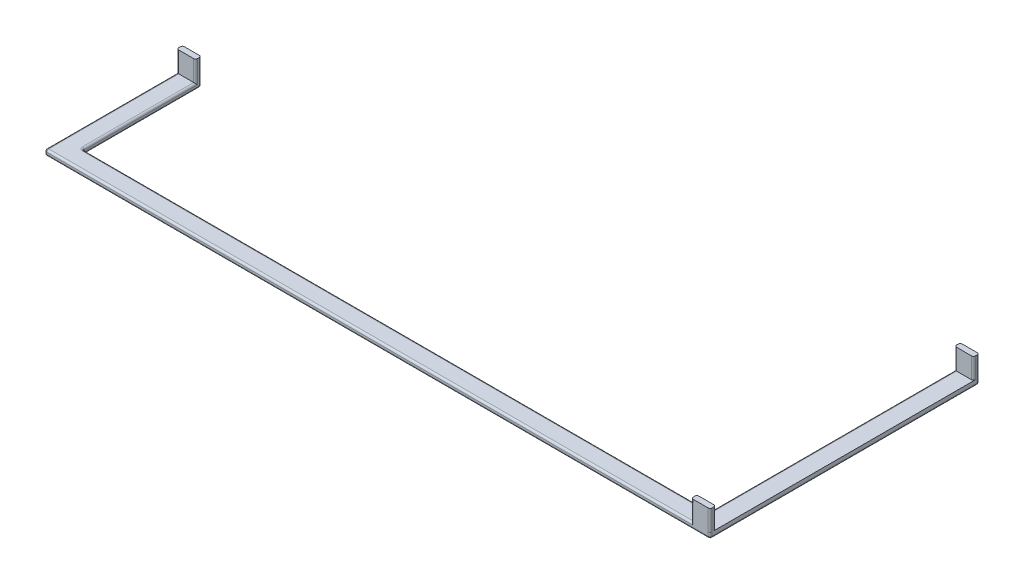
from build123d import *

# Parameters (mm, degrees)
BOSS_EXTRU_1_DEPTH   = 11
BOSS_EXTRU_1_2_DEPTH = 11
BOSS_EXTRU_2_DEPTH   = 3
BOSS_EXTRU_4_DEPTH   = 343.6
BOSS_EXTRU_5_DEPTH   = 63.11
BOSS_EXTRU_6_DEPTH   = 11
CONG_1_R             = 1
CONG_2_R             = 1


with BuildPart() as part:
    # Esquisse1 → Boss.-Extru.1 (new body)
    with BuildSketch(Plane(origin=(0, 0, 0), x_dir=(1, 0, 0), z_dir=(0, 1, 0))):
        with BuildLine():
            Line((0.9999999999999831, 71.50000000000001), (8.999999999999984, 71.50000000000001))
            ThreePointArc((8.999999999999984, 71.50000000000001), (9.707106781186543, 71.20710678118655), (9.999999999999984, 70.5))
            Line((9.999999999999984, 70.5), (9.999999999999984, 69.5))
            ThreePointArc((9.999999999999984, 69.5), (9.707106781186532, 68.79289321881345), (8.999999999999984, 68.5))
            Line((8.999999999999984, 68.5), (0.9999999999999831, 68.5))
            ThreePointArc((0.9999999999999831, 68.5), (0.2928932188134351, 68.79289321881345), (-1.735e-14, 69.5))
            Line((-1.735e-14, 69.5), (-1.735e-14, 70.5))
            ThreePointArc((-1.735e-14, 70.5), (0.29289321881342556, 71.20710678118655), (0.9999999999999831, 71.50000000000001))
        make_face()
    extrude(amount=BOSS_EXTRU_1_DEPTH)



with BuildPart() as body_2:
    # Esquisse1 → Boss.-Extru.1 2 (new body)
    with BuildSketch(Plane(origin=(0, 0, 0), x_dir=(1, 0, 0), z_dir=(0, 1, 0))):
        with BuildLine():
            Line((1.0000000000000004, -68.5), (9.000000000000002, -68.5))
            ThreePointArc((9.000000000000002, -68.5), (9.70710678118655, -68.79289321881345), (10.000000000000002, -69.5))
            Line((10.000000000000002, -69.5), (10.000000000000002, -70.5))
            ThreePointArc((10.000000000000002, -70.5), (9.70710678118656, -71.20710678118655), (9.000000000000002, -71.50000000000001))
            Line((9.000000000000002, -71.50000000000001), (1.0000000000000004, -71.50000000000001))
            ThreePointArc((1.0000000000000004, -71.50000000000001), (0.2928932188134524, -71.20710678118655), (0, -70.5))
            Line((0, -70.5), (0, -69.5))
            ThreePointArc((0, -69.5), (0.292893218813453, -68.79289321881345), (1.0000000000000004, -68.5))
        make_face()
    extrude(amount=BOSS_EXTRU_1_2_DEPTH)


with BuildPart() as part_1:
    add(part.part)

    add(body_2.part)  # Boss.-Extru.2 merges body 2
    # Esquisse2 → Boss.-Extru.2 (add)
    with BuildSketch(Plane.XZ):
        Polygon((-1.727e-14, 71.50000000000001), (9.999999999999984, 71.50000000000001), (10.000000000000002, -71.50000000000001), (2.4e-16, -71.50000000000001), align=None)
    extrude(amount=BOSS_EXTRU_2_DEPTH)

    # Esquisse3 → Boss.-Extru.4 (add)
    with BuildSketch(Plane(origin=(0, 0, 0), x_dir=(0, 0, -1), z_dir=(1, 0, 0))):
        Polygon((-61.50000000000001, -2.9999999999999996), (-71.50000000000001, -3.0000000000000013), (-71.50000000000001, -1.751e-14), (-61.5, -1.648e-14), align=None)
    extrude(amount=-BOSS_EXTRU_4_DEPTH)

    # Esquisse4 → Boss.-Extru.5 (add)
    with BuildSketch(Plane(origin=(0, 1.4225e-13, 61.5), x_dir=(-1, 0, 0), z_dir=(0, -3.47e-15, -1))):
        Polygon((343.6, -3.0000000000001417), (333.6, -3.000000000000143), (333.6, -2.2985e-13), (343.6, -2.2985e-13), align=None)
    extrude(amount=BOSS_EXTRU_5_DEPTH)

    # Esquisse5 → Boss.-Extru.6 (add)
    with BuildSketch(Plane(origin=(0, 0, 0), x_dir=(1, 0, 0), z_dir=(0, 1, 0))):
        with BuildLine():
            Line((-342.6, 1.6100000000000003), (-334.6, 1.6100000000000003))
            ThreePointArc((-334.6, 1.6100000000000003), (-333.89289321881347, 1.3171067811865478), (-333.6, 0.6100000000000004))
            Line((-333.6, 0.6100000000000004), (-333.6, -0.38999999999999974))
            ThreePointArc((-333.6, -0.38999999999999974), (-333.89289321881347, -1.0971067811865471), (-334.6, -1.3899999999999997))
            Line((-334.6, -1.3899999999999997), (-342.6, -1.3899999999999997))
            ThreePointArc((-342.6, -1.3899999999999997), (-343.3071067811866, -1.0971067811865471), (-343.6, -0.38999999999999974))
            Line((-343.6, -0.38999999999999974), (-343.6, 0.6100000000000001))
            ThreePointArc((-343.6, 0.6100000000000001), (-343.3071067811866, 1.3171067811865478), (-342.6, 1.6100000000000003))
        make_face()
    extrude(amount=BOSS_EXTRU_6_DEPTH)

    # Congé1
    cong_1_edges = [part_1.edges().sort_by_distance(p)[0] for p in [
        (-333.6, -1.5000000000002631, -1.6099999999999943),
        (-343.6, -1.5000000000002622, -1.6099999999999943),
        (-343.6, -1.5000000000000093, 71.50000000000001),
        (-333.6, -1.5000000000000442, 61.50000000000001),
        (0, -1.500000000000008, 61.5),
        (2.4e-16, -1.5, -71.50000000000001),
        (10.000000000000002, -1.5, -71.50000000000001),
        (9.999999999999984, -1.5, 71.50000000000001),
    ]]
    fillet(cong_1_edges, radius=CONG_1_R)

    # Congé2
    cong_2_edges = [part_1.edges().sort_by_distance(p)[0] for p in [
        (-166.80000000000004, -2.9999999999999996, 61.50000000000001),
        (-333.3071067811866, 2.45e-15, 61.207106781186546),
        (-333.3071067811866, -2.9999999999999973, 61.20710678118655),
        (-333.6, -3.0000000000001106, 29.945000000000007),
        (-333.89289321881347, -3.0000000000000027, -1.3171067811865385),
        (-338.6, -3.000000000000219, -1.609999999999989),
        (-343.3071067811866, -3.0000000000000027, -1.317106781186539),
        (-343.6, -3.00000000000011, 34.94500000000001),
        (-343.3071067811866, 0, 71.20710678118657),
        (-343.3071067811866, -3, 71.20710678118657),
        (-333.6, -1.9535e-13, 30.444999999999997),
        (-343.6, -1.6006e-13, 35.44500000000001),
        (-170.8, -8.73e-15, 71.50000000000001),
        (-166.8, -3.000000000000001, 71.50000000000001),
        (-166.80000000000004, -1.648e-14, 61.5),
        (9.707106781186534, -3, 71.20710678118655),
        (9.999999999999993, -3, 0),
        (9.70710678118655, -3, -71.20710678118657),
        (5.000000000000001, -3, -71.50000000000001),
        (0.2928932188134524, -3, -71.20710678118657),
        (-7.9e-15, -3, -5.000000000000014),
        (-0.29289321881346586, -2.9999999999999982, 61.207106781186546),
        (-0.29289321881346586, 1.67e-15, 61.20710678118654),
        (-7.96e-15, 0, -4.5),
    ]]
    fillet(cong_2_edges, radius=CONG_2_R)


solid = part_1.part
